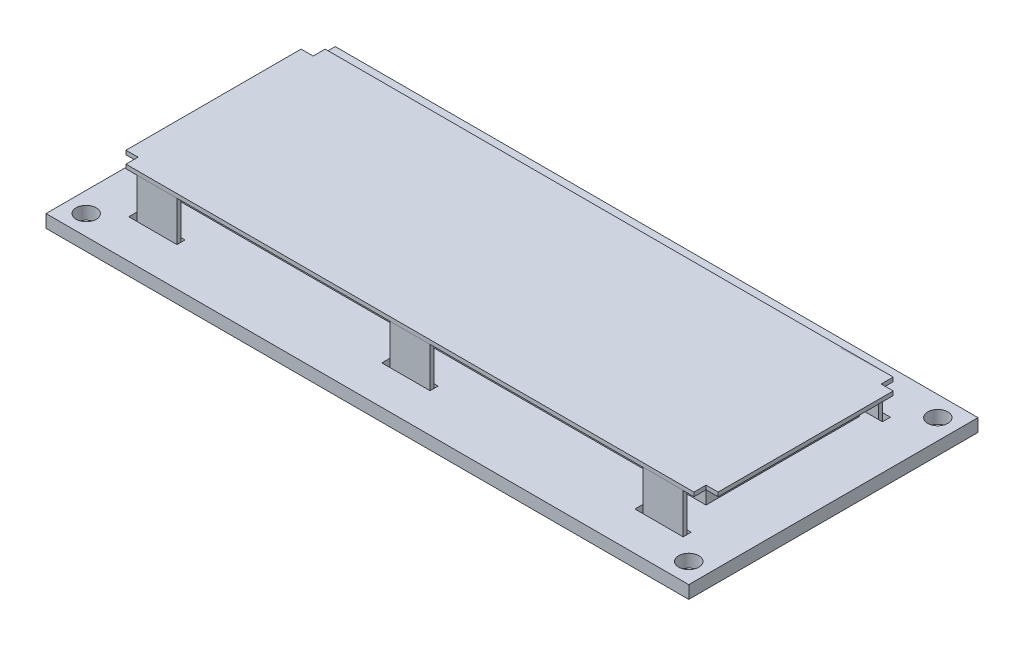
from build123d import *

# Parameters (mm, degrees)
SKIZZE1_W                        = 36
SKIZZE1_H                        = 1.6
LINEAR_AUSTRAGEN1_DEPTH          = 40
F_2_5_2_5_DURCHMESSER_BOHRUNG1_D = 2.5
SKIZZE7_W                        = 3
SKIZZE7_H                        = 1
SKIZZE7_W_2                      = 6
LINEAR_AUSTRAGEN4_DEPTH          = 2.6
LINEAR_START                     = 4.5
LINEAR_AUSTRAGEN2_DEPTH          = 0.5
LINEAR_AUSTRAGEN3_DEPTH          = 11
LINEAR_AUSTRAGEN3_2_DEPTH        = 11
LINEAR_AUSTRAGEN3_3_DEPTH        = 11
LINEAR_AUSTRAGEN3_4_DEPTH        = 11
LINEAR_AUSTRAGEN3_5_DEPTH        = 11
LINEAR_AUSTRAGEN3_6_DEPTH        = 11
SKIZZE8_W                        = 68
SKIZZE8_H                        = 19.1
LINEAR_AUSTRAGEN5_DEPTH          = 3
LINEARES_MUSTER1_COUNT           = 16
LINEARES_MUSTER1_PITCH           = 2.54


with BuildPart() as part:
    # Skizze1 → Linear austragen1 (new body)
    with BuildSketch(Plane(origin=(0, 0, 0), x_dir=(0, 0, -1), z_dir=(1, 0, 0))):
        with Locations((18, -0.8)):
            Rectangle(SKIZZE1_W, SKIZZE1_H)
    linear_austragen1 = extrude(amount=LINEAR_AUSTRAGEN1_DEPTH)

    # Ø2.5 (2.5) Durchmesser Bohrung1 (through all)
    with Locations(Plane(origin=(37.5, 0, -2.5), x_dir=(0, 0, 1), z_dir=(0, 1, 0))):
        with Locations((0, 0), (-31, 0)):
            f_2_5_2_5_durchmesser_bohrung1 = Hole(F_2_5_2_5_DURCHMESSER_BOHRUNG1_D / 2)

    # Skizze7 → Linear austragen4 (cut, through all)
    with BuildSketch(Plane(origin=(0, 0, 0), x_dir=(1, 0, 0), z_dir=(0, 1, 0))):
        with Locations((1.5, 30.1)):
            Rectangle(SKIZZE7_W, SKIZZE7_H)
        with Locations((31.5, 30.1)):
            Rectangle(SKIZZE7_W_2, SKIZZE7_H)
        with Locations((31.5, 5.3)):
            Rectangle(SKIZZE7_W_2, SKIZZE7_H)
        with Locations((1.5, 5.3)):
            Rectangle(SKIZZE7_W, SKIZZE7_H)
    linear_austragen4 = extrude(amount=-LINEAR_AUSTRAGEN4_DEPTH, mode=Mode.SUBTRACT)

    # Spiegeln1: Linear austragen1, Ø2.5 (2.5) Durchmesser Bohrung1, Linear austragen4 across plane
    add(linear_austragen1.mirror(Plane(origin=(0, -1.6, 0), x_dir=(0, 0, 1), z_dir=(1, 0, 0))))
    add(f_2_5_2_5_durchmesser_bohrung1.mirror(Plane(origin=(0, -1.6, 0), x_dir=(0, 0, 1), z_dir=(1, 0, 0))), mode=Mode.SUBTRACT)
    add(linear_austragen4.mirror(Plane(origin=(0, -1.6, 0), x_dir=(0, 0, 1), z_dir=(1, 0, 0))), mode=Mode.SUBTRACT)

    # Skizze9 → Ø1.0 (1) Durchmesser Bohrung1 (revolve, cut)
    with BuildSketch(Plane(origin=(-32, 0, -33.5), x_dir=(0, 0, 1), z_dir=(1, 0, 0))):
        Polygon((0, 0), (0, 1.90043031), (0.5, 1.6), (0.5, 0), align=None)
    f_1_0_1_durchmesser_bohrung1 = revolve(axis=Axis((-32, 6.35, -33.5), (0, -1, 0)), mode=Mode.SUBTRACT)

    # Lineares Muster1: Ø1.0 (1) Durchmesser Bohrung1 ×16
    with Locations(*[(i * LINEARES_MUSTER1_PITCH, 0, 0) for i in range(1, LINEARES_MUSTER1_COUNT)]):
        add(f_1_0_1_durchmesser_bohrung1, mode=Mode.SUBTRACT)


with BuildPart() as body_2:
    # Skizze5 → Linear austragen2 (new body)
    with BuildSketch(Plane(origin=(0, 0, 0), x_dir=(1, 0, 0), z_dir=(0, 1, 0)).offset(LINEAR_START)):
        Polygon((0, 30.1), (35.35, 30.1), (35.35, 28.6), (36.85, 28.6), (36.85, 6.8), (35.35, 6.8), (35.35, 5.3), (0, 5.3), align=None)
    linear_austragen2 = extrude(amount=LINEAR_AUSTRAGEN2_DEPTH)

    # Spiegeln8: Linear austragen2 across plane
    add(linear_austragen2.mirror(Plane(origin=(0, 5, -5.3), x_dir=(0, 0, 1), z_dir=(1, 0, 0))))

    # Skizze8 → Linear austragen5 (add)
    with BuildSketch(Plane.XZ.offset(-4.5)):
        with Locations((0, -17.7)):
            Rectangle(SKIZZE8_W, SKIZZE8_H)
    extrude(amount=LINEAR_AUSTRAGEN5_DEPTH)


with BuildPart() as body_3:
    # Skizze6 → Linear austragen3 (new body)
    with BuildSketch(Plane(origin=(0, 5, 0), x_dir=(1, 0, 0), z_dir=(0, 1, 0))):
        Polygon((2.5, 30.1), (0, 30.1), (-2.5, 30.1), (-2.5, 29.6), (2.5, 29.6), align=None)
    extrude(amount=-LINEAR_AUSTRAGEN3_DEPTH)


with BuildPart() as body_4:
    # Skizze6 → Linear austragen3 2 (new body)
    with BuildSketch(Plane(origin=(0, 5, 0), x_dir=(1, 0, 0), z_dir=(0, 1, 0))):
        Polygon((0, 5.3), (2.5, 5.3), (2.5, 5.8), (-2.5, 5.8), (-2.5, 5.3), align=None)
    extrude(amount=-LINEAR_AUSTRAGEN3_2_DEPTH)


with BuildPart() as body_5:
    # Skizze6 → Linear austragen3 3 (new body)
    with BuildSketch(Plane(origin=(0, 5, 0), x_dir=(1, 0, 0), z_dir=(0, 1, 0))):
        Polygon((34, 30.1), (31.5, 30.1), (29, 30.1), (29, 29.6), (34, 29.6), align=None)
    extrude(amount=-LINEAR_AUSTRAGEN3_3_DEPTH)


with BuildPart() as body_6:
    # Skizze6 → Linear austragen3 4 (new body)
    with BuildSketch(Plane(origin=(0, 5, 0), x_dir=(1, 0, 0), z_dir=(0, 1, 0))):
        Polygon((31.5, 5.3), (34, 5.3), (34, 5.8), (29, 5.8), (29, 5.3), align=None)
    extrude(amount=-LINEAR_AUSTRAGEN3_4_DEPTH)


with BuildPart() as body_7:
    # Skizze6 → Linear austragen3 5 (new body)
    with BuildSketch(Plane(origin=(0, 5, 0), x_dir=(1, 0, 0), z_dir=(0, 1, 0))):
        Polygon((-29, 30.1), (-31.5, 30.1), (-34, 30.1), (-34, 29.6), (-29, 29.6), align=None)
    extrude(amount=-LINEAR_AUSTRAGEN3_5_DEPTH)


with BuildPart() as body_8:
    # Skizze6 → Linear austragen3 6 (new body)
    with BuildSketch(Plane(origin=(0, 5, 0), x_dir=(1, 0, 0), z_dir=(0, 1, 0))):
        Polygon((-31.5, 5.3), (-29, 5.3), (-29, 5.8), (-34, 5.8), (-34, 5.3), align=None)
    extrude(amount=-LINEAR_AUSTRAGEN3_6_DEPTH)


solid = Compound([part.part, body_2.part, body_3.part, body_4.part, body_5.part, body_6.part, body_7.part, body_8.part])
